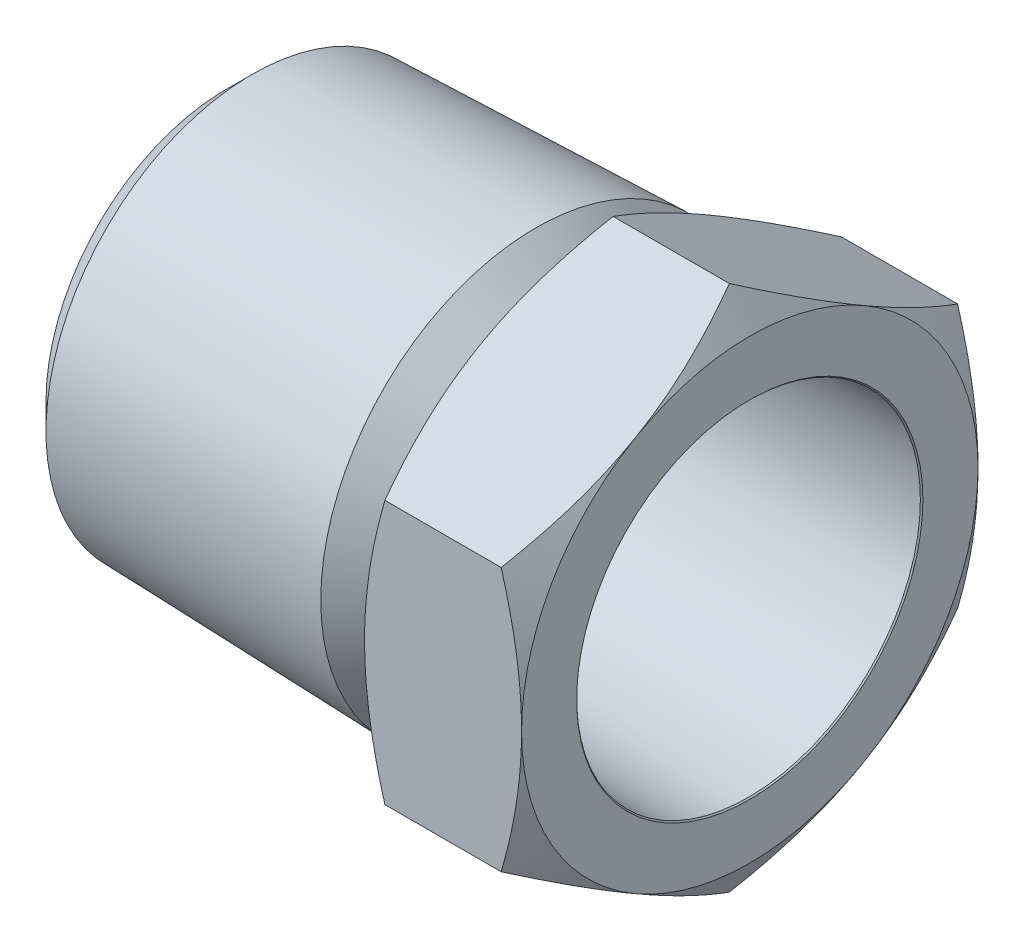
from build123d import *

# Parameters (mm, degrees)
SKETCH2_R          = 8.5725
EXTRUDE1_DEPTH     = 21.844
EXTRUDE1_TAPER     = -1.783333333
SKETCH5_OUTSIDE_W  = 73.012
SKETCH5_OUTSIDE_H  = 73.012
SKETCH5_OUTSIDE_R  = 7.528956448
CUT_EXTRUDE1_DEPTH = 22.8440001
CUT_EXTRUDE1_TAPER = 45
SKETCH8_R          = 14.9225
CUT_EXTRUDE4_DEPTH = 7.5532001
SKETCH9_OUTSIDE_W  = 26.06
SKETCH9_OUTSIDE_H  = 26.06
SKETCH9_OUTSIDE_R  = 7.655956448
CUT_EXTRUDE5_DEPTH = 1.058333333
SKETCH10_OUTSIDE_W = 56.444
SKETCH10_OUTSIDE_H = 56.444
SKETCH10_OUTSIDE_R = 7.655956448
CUT_EXTRUDE6_DEPTH = 15.232466767
CUT_EXTRUDE6_TAPER = 45
EXTRUDE2_DEPTH     = 6.5532
SKETCH7_OUTSIDE_W  = 107.462
SKETCH7_OUTSIDE_H  = 110.41
SKETCH7_OUTSIDE_R  = 9.525
CUT_EXTRUDE2_DEPTH = 22.8440001
CUT_EXTRUDE2_TAPER = 60
SKETCH18_OUTSIDE_W = 62.968
SKETCH18_OUTSIDE_H = 65.916
SKETCH18_OUTSIDE_R = 9.525
EXTRUDE3_DEPTH     = 10
EXTRUDE3_TAPER     = 60
SKETCH11_R         = 6.858
CUT_EXTRUDE7_DEPTH = 11.16
CUT_EXTRUDE7_TAPER = -1.783333333
SKETCH16_R         = 7.225132547
CUT_EXTRUDE9_DEPTH = 6.35
CUT_EXTRUDE9_TAPER = 45
SKETCH17_W         = 11.684
SKETCH17_H         = 6.399728224


with BuildPart() as part:
    # Sketch2 → Extrude1 (new body)
    with BuildSketch(Plane(origin=(-10.922, 0, 0), x_dir=(0, 0, -1), z_dir=(1, 0, 0))):
        Circle(SKETCH2_R)
    extrude(amount=EXTRUDE1_DEPTH, taper=EXTRUDE1_TAPER)

    # Sketch5 outside → Cut-Extrude1 (cut, through all)
    with BuildSketch(Plane(origin=(-10.922, 0, 0), x_dir=(0, 0, -1), z_dir=(1, 0, 0))):
        Rectangle(SKETCH5_OUTSIDE_W, SKETCH5_OUTSIDE_H)
        Circle(SKETCH5_OUTSIDE_R, mode=Mode.SUBTRACT)
    extrude(amount=CUT_EXTRUDE1_DEPTH, taper=CUT_EXTRUDE1_TAPER, mode=Mode.SUBTRACT)

    # Sketch8 → Cut-Extrude4 (cut, through all)
    with BuildSketch(Plane(origin=(4.3688, 0, 0), x_dir=(0, 0, -1), z_dir=(1, 0, 0))):
        Circle(SKETCH8_R)
    extrude(amount=CUT_EXTRUDE4_DEPTH, mode=Mode.SUBTRACT)

    # Sketch9 outside → Cut-Extrude5 (cut)
    with BuildSketch(Plane(origin=(4.3688, 0, 0), x_dir=(0, 0, -1), z_dir=(1, 0, 0))):
        Rectangle(SKETCH9_OUTSIDE_W, SKETCH9_OUTSIDE_H)
        Circle(SKETCH9_OUTSIDE_R, mode=Mode.SUBTRACT)
    extrude(amount=-CUT_EXTRUDE5_DEPTH, mode=Mode.SUBTRACT)

    # Sketch10 outside → Cut-Extrude6 (cut, through all)
    with BuildSketch(Plane(origin=(3.310466667, 0, 0), x_dir=(0, 0, -1), z_dir=(1, 0, 0))):
        Rectangle(SKETCH10_OUTSIDE_W, SKETCH10_OUTSIDE_H)
        Circle(SKETCH10_OUTSIDE_R, mode=Mode.SUBTRACT)
    extrude(amount=-CUT_EXTRUDE6_DEPTH, taper=CUT_EXTRUDE6_TAPER, mode=Mode.SUBTRACT)

    # Sketch6 → Extrude2 (add)
    with BuildSketch(Plane(origin=(10.922, 0, 0), x_dir=(0, 0, -1), z_dir=(1, 0, 0))):
        Polygon((0, 10.998522628), (-9.525, 5.499261314), (-9.525, -5.499261314), (0, -10.998522628), (9.525, -5.499261314), (9.525, 5.499261314), align=None)
    extrude(amount=-EXTRUDE2_DEPTH)

    # Sketch7 outside → Cut-Extrude2 (cut, through all)
    with BuildSketch(Plane(origin=(10.922, 0, 0), x_dir=(0, 0, -1), z_dir=(1, 0, 0))):
        Rectangle(SKETCH7_OUTSIDE_W, SKETCH7_OUTSIDE_H)
        Circle(SKETCH7_OUTSIDE_R, mode=Mode.SUBTRACT)
    extrude(amount=-CUT_EXTRUDE2_DEPTH, taper=CUT_EXTRUDE2_TAPER, mode=Mode.SUBTRACT)

    # Sketch18 outside → Extrude3 (cut)
    with BuildSketch(Plane.ZY.offset(-4.3688)):
        Rectangle(SKETCH18_OUTSIDE_W, SKETCH18_OUTSIDE_H)
        Circle(SKETCH18_OUTSIDE_R, mode=Mode.SUBTRACT)
    extrude(amount=-EXTRUDE3_DEPTH, taper=EXTRUDE3_TAPER, mode=Mode.SUBTRACT)

    # Sketch11 → Cut-Extrude7 (cut, through all)
    with BuildSketch(Plane(origin=(0.762, 0, 0), x_dir=(0, 0, -1), z_dir=(1, 0, 0))):
        Circle(SKETCH11_R)
    extrude(amount=CUT_EXTRUDE7_DEPTH, taper=CUT_EXTRUDE7_TAPER, mode=Mode.SUBTRACT)

    # Sketch16 → Cut-Extrude9 (cut)
    with BuildSketch(Plane(origin=(10.922, 0, 0), x_dir=(0, 0, -1), z_dir=(1, 0, 0))):
        Circle(SKETCH16_R)
    extrude(amount=-CUT_EXTRUDE9_DEPTH, taper=CUT_EXTRUDE9_TAPER, mode=Mode.SUBTRACT)

    # Sketch17 → Cut-Revolve1 (revolve, cut)
    with BuildSketch(Plane.XY):
        with Locations((-5.08, 3.199864112)):
            Rectangle(SKETCH17_W, SKETCH17_H)
    revolve(axis=Axis((-10.922, 0, 0), (1, 0, 0)), mode=Mode.SUBTRACT)


solid = part.part
